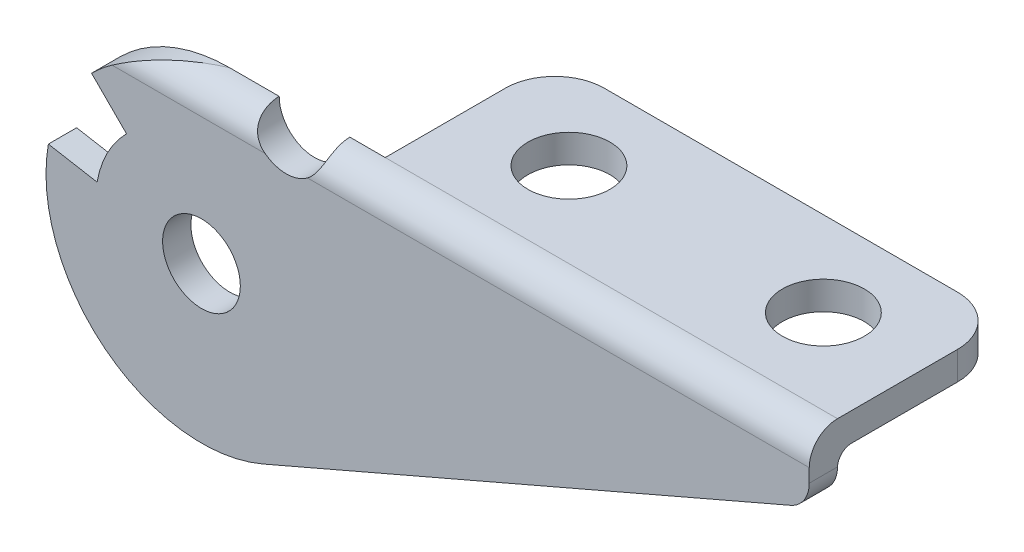
from build123d import *

# Parameters (mm, degrees)
SKETCH1_R               = 2.75
BOSS_EXTRUDE1_DEPTH     = 14
CUT_EXTRUDE1_DEPTH      = 65
CUT_EXTRUDE1_DEPTH_BACK = 65
SKETCH2_W               = 24
SKETCH2_H               = 32
SKETCH3_W               = 64
SKETCH3_H               = 24
CUT_EXTRUDE2_DEPTH      = 22
CUT_EXTRUDE3_DEPTH      = 2
CUT_EXTRUDE3_DEPTH_BACK = 2
SKETCH4_R               = 2.9
CUT_EXTRUDE4_DEPTH      = 2
CUT_EXTRUDE4_DEPTH_BACK = 2
SKETCH5_R               = 2.9
SKETCH6_R               = 2.5
CUT_EXTRUDE5_DEPTH      = 14


with BuildPart() as part:
    # Sketch1 → Boss-Extrude1 (new body)
    with BuildSketch(Plane.XY):
        with BuildLine():
            Line((4.363786096, 0.902605737), (41.672757219, 17.026406116))
            ThreePointArc((41.672757219, 17.026406116), (42.63848659, 17.837594003), (43, 19.045884969))
            Line((43, 19.045884969), (43, 22))
            Line((43, 22), (0, 22))
            ThreePointArc((0, 22), (-4.209517756, 21.162674858), (-7.778174593, 18.778174593))
            Line((-7.778174593, 18.778174593), (-5.303300859, 16.303300859))
            ThreePointArc((-5.303300859, 16.303300859), (-6.652581249, 14.463114599), (-7.386058148, 12.302361333))
            Line((-7.386058148, 12.302361333), (-10.832885283, 12.910129954))
            ThreePointArc((-10.832885283, 12.910129954), (-6.819638592, 2.369094516), (4.363786096, 0.902605737))
        make_face()
        with Locations((0, 11)):
            Circle(SKETCH1_R, mode=Mode.SUBTRACT)
    extrude(amount=-BOSS_EXTRUDE1_DEPTH)

    # Sketch2 → Cut-Extrude1 (cut, two sides: drawn at the far end of the back side and taken through both)
    with BuildSketch(Plane(origin=(0, 0, 0), x_dir=(0, 0, -1), z_dir=(1, 0, 0)).offset(-CUT_EXTRUDE1_DEPTH_BACK)):
        with Locations((7, 11)):
            Rectangle(SKETCH2_W, SKETCH2_H)
        with BuildLine():
            Line((0, 0), (2, 0))
            Line((2, 0), (2, 19))
            ThreePointArc((2, 19), (2.292893219, 19.707106781), (3, 20))
            Line((3, 20), (14, 20))
            Line((14, 20), (14, 22))
            Line((14, 22), (2, 22))
            ThreePointArc((2, 22), (0.585786438, 21.414213562), (0, 20))
            Line((0, 20), (0, 0))
        make_face(mode=Mode.SUBTRACT)
    extrude(amount=CUT_EXTRUDE1_DEPTH + CUT_EXTRUDE1_DEPTH_BACK, mode=Mode.SUBTRACT)

    # Sketch3 → Cut-Extrude2 (cut)
    with BuildSketch(Plane(origin=(0, 0, 0), x_dir=(-1, 0, 0), z_dir=(0, 1, 0))):
        with Locations((-16, -7)):
            Rectangle(SKETCH3_W, SKETCH3_H)
        with BuildLine():
            Line((11, 0), (-43, 0))
            Line((-43, 0), (-43, -10.5))
            ThreePointArc((-43, -10.5), (-41.974873734, -12.974873734), (-39.5, -14))
            Line((-39.5, -14), (-14.5, -14))
            ThreePointArc((-14.5, -14), (-12.025126266, -12.974873734), (-11, -10.5))
            Line((-11, -10.5), (-11, -2))
            Line((-11, -2), (11, -2))
            Line((11, -2), (11, 0))
        make_face(mode=Mode.SUBTRACT)
    extrude(amount=CUT_EXTRUDE2_DEPTH, mode=Mode.SUBTRACT)

    # Sketch4 → Cut-Extrude3 (cut, two sides: drawn at the far end of the back side and taken through both)
    with BuildSketch(Plane(origin=(0, 22, 0), x_dir=(-1, 0, 0), z_dir=(0, 1, 0)).offset(-CUT_EXTRUDE3_DEPTH_BACK)):
        with Locations((-18, -8)):
            Circle(SKETCH4_R)
    extrude(amount=CUT_EXTRUDE3_DEPTH + CUT_EXTRUDE3_DEPTH_BACK, mode=Mode.SUBTRACT)

    # Sketch5 → Cut-Extrude4 (cut, two sides: drawn at the far end of the back side and taken through both)
    with BuildSketch(Plane(origin=(0, 22, 0), x_dir=(-1, 0, 0), z_dir=(0, 1, 0)).offset(-CUT_EXTRUDE4_DEPTH_BACK)):
        with Locations((-36, -8)):
            Circle(SKETCH5_R)
    extrude(amount=CUT_EXTRUDE4_DEPTH + CUT_EXTRUDE4_DEPTH_BACK, mode=Mode.SUBTRACT)

    # Sketch6 → Cut-Extrude5 (cut)
    with BuildSketch(Plane.XY):
        with Locations((6, 22)):
            Circle(SKETCH6_R)
    extrude(amount=-CUT_EXTRUDE5_DEPTH, mode=Mode.SUBTRACT)


solid = part.part
